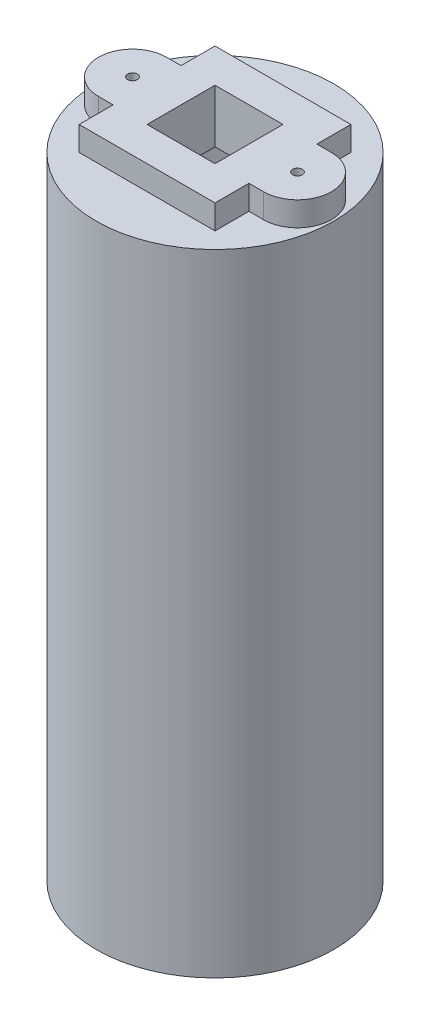
from build123d import *

# Parameters (mm, degrees)
SKETCH1_R               = 12.25
SKETCH1_R_2             = 10.5
BOSS_EXTRUDE1_DEPTH     = 62
SKETCH2_R               = 12.25
BOSS_EXTRUDE2_DEPTH     = 3
SKETCH8_W               = 14
SKETCH8_H               = 14
SKETCH8_R               = 0.5
BOSS_EXTRUDE5_DEPTH     = 2.5
SKETCH9_W               = 7
SKETCH9_H               = 7
CUT_EXTRUDE3_DEPTH      = 1
CUT_EXTRUDE3_DEPTH_BACK = 68.5


with BuildPart() as part:
    # Sketch1 → Boss-Extrude1 (new body)
    with BuildSketch(Plane(origin=(0, 0, 0), x_dir=(1, 0, 0), z_dir=(0, 1, 0))):
        Circle(SKETCH1_R)
        Circle(SKETCH1_R_2, mode=Mode.SUBTRACT)
    extrude(amount=BOSS_EXTRUDE1_DEPTH)

    # Sketch2 → Boss-Extrude2 (add)
    with BuildSketch(Plane(origin=(0, 62, 0), x_dir=(1, 0, 0), z_dir=(0, 1, 0))):
        Circle(SKETCH2_R)
    extrude(amount=BOSS_EXTRUDE2_DEPTH)

    # Sketch8 → Boss-Extrude5 (add)
    with BuildSketch(Plane(origin=(0, 65, 0), x_dir=(1, 0, 0), z_dir=(0, 1, 0))):
        Rectangle(SKETCH8_W, SKETCH8_H)
        with BuildLine():
            Line((-8.5, 3.5), (8.5, 3.5))
            ThreePointArc((8.5, 3.5), (12, 0), (8.5, -3.5))
            Line((8.5, -3.5), (-8.5, -3.5))
            ThreePointArc((-8.5, -3.5), (-12, 0), (-8.5, 3.5))
        make_face()
        with Locations((8.5, 0)):
            Circle(SKETCH8_R, mode=Mode.SUBTRACT)
        with Locations((-8.5, 0)):
            Circle(SKETCH8_R, mode=Mode.SUBTRACT)
    extrude(amount=BOSS_EXTRUDE5_DEPTH)

    # Sketch9 → Cut-Extrude3 (cut, two sides)
    with BuildSketch(Plane(origin=(0, 67.5, 0), x_dir=(1, 0, 0), z_dir=(0, 1, 0))) as cut_extrude3_sk:
        Rectangle(SKETCH9_W, SKETCH9_H)
    extrude(amount=CUT_EXTRUDE3_DEPTH, mode=Mode.SUBTRACT)
    extrude(cut_extrude3_sk.sketch, amount=-CUT_EXTRUDE3_DEPTH_BACK, mode=Mode.SUBTRACT)


solid = part.part
